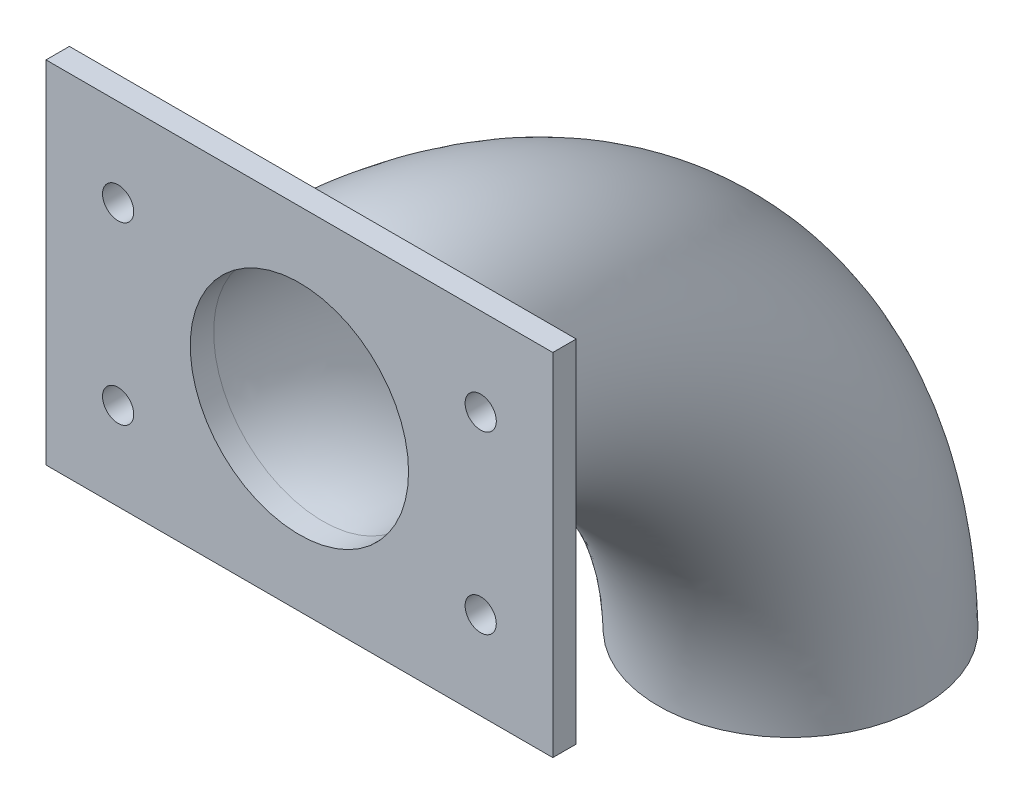
from build123d import *

# Parameters (mm, degrees)
ESQUISSE1_R        = 17
ESQUISSE1_R_2      = 14
ESQUISSE3_W        = 65
ESQUISSE3_H        = 45
ESQUISSE3_R        = 14
ESQUISSE3_R_2      = 2
BOSS_EXTRU_1_DEPTH = 3


with BuildPart() as part:
    # Balayage1: sweep along a path in Esquisse2
    with BuildLine(Plane(origin=(0, 0, 0), x_dir=(0, 0, -1), z_dir=(1, 0, 0))) as balayage1_path:
        ThreePointArc((0, 0), (41.597979746, -15.573593129), (60, -56))
    # Esquisse1 → Balayage1 (sweep)
    with BuildSketch(Plane.XY):
        Circle(ESQUISSE1_R)
        Circle(ESQUISSE1_R_2, mode=Mode.SUBTRACT)
    sweep(path=balayage1_path.line)

    # Esquisse3 → Boss.-Extru.1 (add)
    with BuildSketch(Plane.XY):
        Rectangle(ESQUISSE3_W, ESQUISSE3_H)
        Circle(ESQUISSE3_R, mode=Mode.SUBTRACT)
        with Locations((-23.25, 11.25)):
            Circle(ESQUISSE3_R_2, mode=Mode.SUBTRACT)
        with Locations((-23.25, -11.25)):
            Circle(ESQUISSE3_R_2, mode=Mode.SUBTRACT)
        with Locations((23.25, -11.25)):
            Circle(ESQUISSE3_R_2, mode=Mode.SUBTRACT)
        with Locations((23.25, 11.25)):
            Circle(ESQUISSE3_R_2, mode=Mode.SUBTRACT)
    extrude(amount=BOSS_EXTRU_1_DEPTH)


solid = part.part
